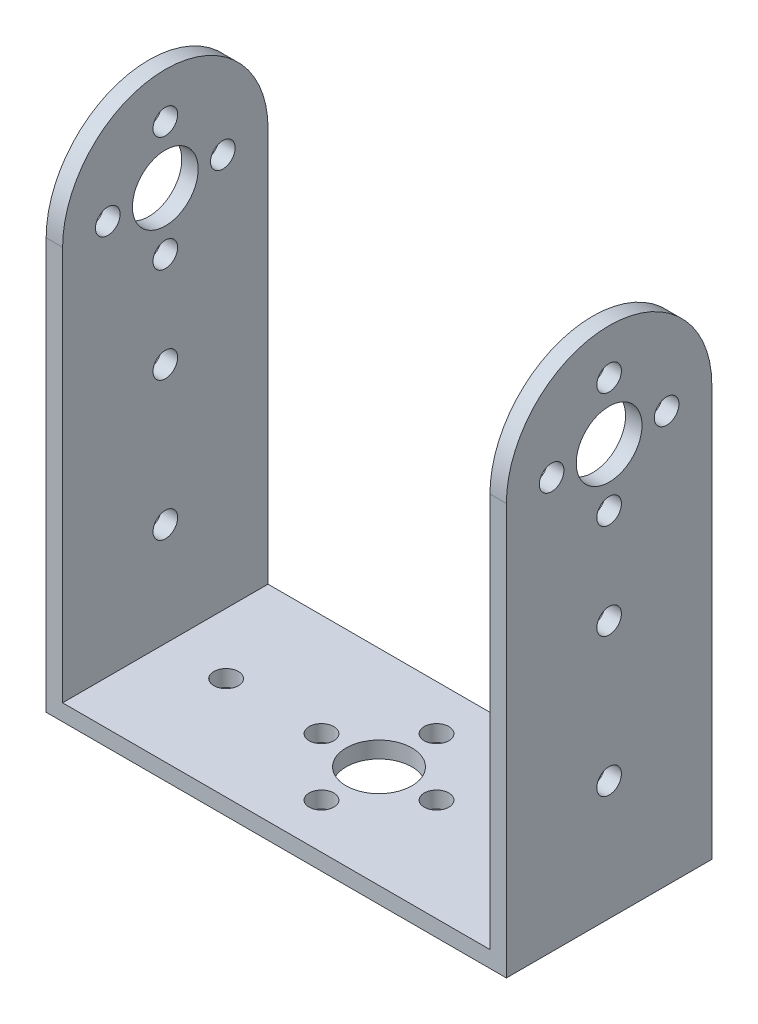
from build123d import *

# Parameters (mm, degrees)
SKETCH1_W           = 52
SKETCH1_H           = 25
SKETCH1_R           = 4
SKETCH1_R_2         = 1.5
BOSS_EXTRUDE1_DEPTH = 2
SKETCH3_R           = 4
SKETCH3_R_2         = 1.5
BOSS_EXTRUDE2_DEPTH = 2
SKETCH4_R           = 4
SKETCH4_R_2         = 1.5
BOSS_EXTRUDE3_DEPTH = 2


with BuildPart() as part:
    # Sketch1 → Boss-Extrude1 (new body)
    with BuildSketch(Plane(origin=(0, 0, 0), x_dir=(1, 0, 0), z_dir=(0, 1, 0))):
        Rectangle(SKETCH1_W, SKETCH1_H)
        Circle(SKETCH1_R, mode=Mode.SUBTRACT)
        with Locations((18.6, 0)):
            Circle(SKETCH1_R_2, mode=Mode.SUBTRACT)
        with Locations((0, 7)):
            Circle(SKETCH1_R_2, mode=Mode.SUBTRACT)
        with Locations((7, 0)):
            Circle(SKETCH1_R_2, mode=Mode.SUBTRACT)
        with Locations((0, -7)):
            Circle(SKETCH1_R_2, mode=Mode.SUBTRACT)
        with Locations((-7, 0)):
            Circle(SKETCH1_R_2, mode=Mode.SUBTRACT)
        with Locations((-18.6, 0)):
            Circle(SKETCH1_R_2, mode=Mode.SUBTRACT)
    extrude(amount=BOSS_EXTRUDE1_DEPTH)

    # Sketch3 → Boss-Extrude2 (add)
    with BuildSketch(Plane(origin=(26, 0, 0), x_dir=(0, 0, -1), z_dir=(1, 0, 0))):
        with BuildLine():
            Line((-12.5, 0), (12.5, 0))
            Line((12.5, 0), (12.5, 50))
            ThreePointArc((12.5, 50), (0, 62.5), (-12.5, 50))
            Line((-12.5, 50), (-12.5, 0))
        make_face()
        with Locations((0, 50)):
            Circle(SKETCH3_R, mode=Mode.SUBTRACT)
        with Locations((0, 43)):
            Circle(SKETCH3_R_2, mode=Mode.SUBTRACT)
        with Locations((7, 50)):
            Circle(SKETCH3_R_2, mode=Mode.SUBTRACT)
        with Locations((0, 57)):
            Circle(SKETCH3_R_2, mode=Mode.SUBTRACT)
        with Locations((-7, 50)):
            Circle(SKETCH3_R_2, mode=Mode.SUBTRACT)
        with Locations((0, 31.4)):
            Circle(SKETCH3_R_2, mode=Mode.SUBTRACT)
        with Locations((0, 14.53)):
            Circle(SKETCH3_R_2, mode=Mode.SUBTRACT)
    extrude(amount=BOSS_EXTRUDE2_DEPTH)

    # Sketch4 → Boss-Extrude3 (add)
    with BuildSketch(Plane.ZY.offset(26)):
        with BuildLine():
            Line((-12.5, 0), (12.5, 0))
            Line((12.5, 0), (12.5, 50))
            ThreePointArc((12.5, 50), (0, 62.5), (-12.5, 50))
            Line((-12.5, 50), (-12.5, 0))
        make_face()
        with Locations((0, 50)):
            Circle(SKETCH4_R, mode=Mode.SUBTRACT)
        with Locations((0, 57)):
            Circle(SKETCH4_R_2, mode=Mode.SUBTRACT)
        with Locations((7, 50)):
            Circle(SKETCH4_R_2, mode=Mode.SUBTRACT)
        with Locations((-7, 50)):
            Circle(SKETCH4_R_2, mode=Mode.SUBTRACT)
        with Locations((0, 43)):
            Circle(SKETCH4_R_2, mode=Mode.SUBTRACT)
        with Locations((0, 31.4)):
            Circle(SKETCH4_R_2, mode=Mode.SUBTRACT)
        with Locations((0, 14.53)):
            Circle(SKETCH4_R_2, mode=Mode.SUBTRACT)
    extrude(amount=BOSS_EXTRUDE3_DEPTH)


solid = part.part
